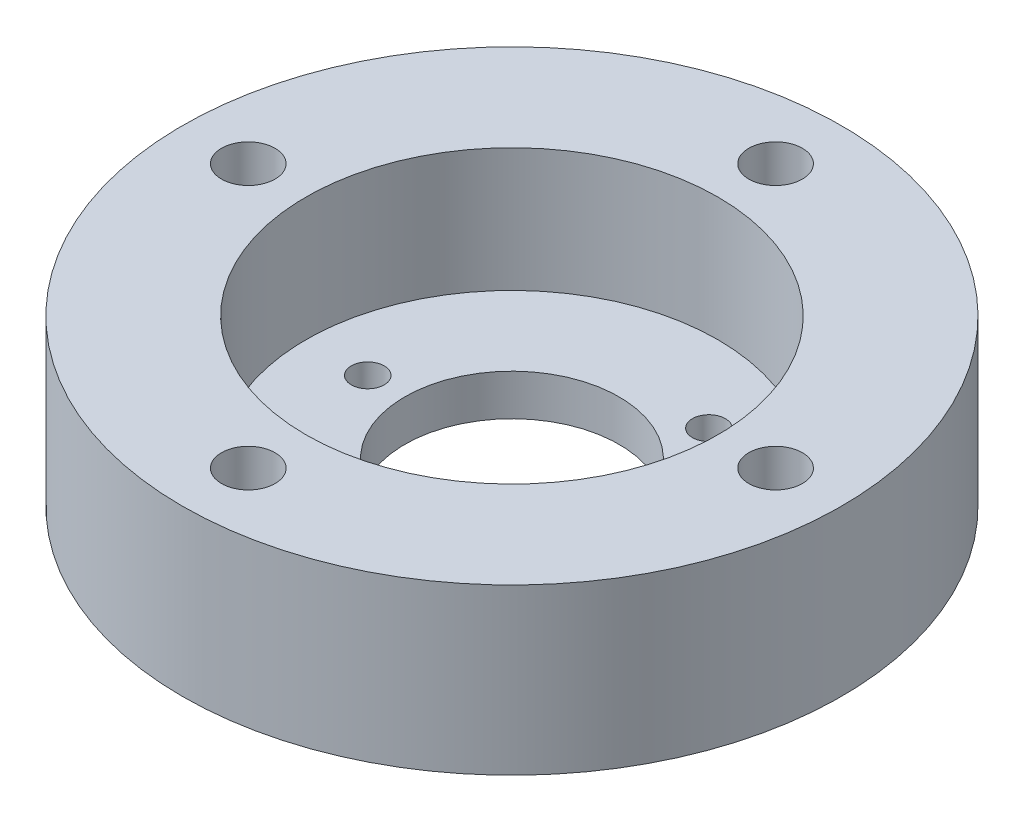
from build123d import *

# Parameters (mm, degrees)
SKETCH2_R          = 2
CUT_EXTRUDE1_DEPTH = 21
SKETCH3_R          = 3.25
CUT_EXTRUDE2_DEPTH = 21
CIRPATTERN1_COUNT  = 4
CIRPATTERN2_COUNT  = 3


with BuildPart() as part:
    # Sketch1 → Revolve1 (revolve)
    with BuildSketch(Plane.XY):
        Polygon((13, 0), (13, 5), (25, 5), (25, 20), (40, 20), (40, 0), align=None)
    revolve(axis=Axis((0, 51.395093442, 0), (0, -1, 0)))

    # Sketch2 → Cut-Extrude1 (cut, through all)
    with BuildSketch(Plane(origin=(0, 20, 0), x_dir=(1, 0, 0), z_dir=(0, 1, 0))):
        with Locations((-17.5, 0)):
            Circle(SKETCH2_R)
    cut_extrude1 = extrude(amount=-CUT_EXTRUDE1_DEPTH, mode=Mode.SUBTRACT)

    # Sketch3 → Cut-Extrude2 (cut, through all)
    with BuildSketch(Plane(origin=(0, 20, 0), x_dir=(1, 0, 0), z_dir=(0, 1, 0))):
        with Locations((0, 32)):
            Circle(SKETCH3_R)
    cut_extrude2 = extrude(amount=-CUT_EXTRUDE2_DEPTH, mode=Mode.SUBTRACT)

    # CirPattern1: Cut-Extrude2 ×4 about axis
    cirpattern1_axis = Axis((0, 0, 0), (0, 1, 0))
    for i in range(1, CIRPATTERN1_COUNT):
        add(cut_extrude2.rotate(cirpattern1_axis, i * 360 / CIRPATTERN1_COUNT), mode=Mode.SUBTRACT)

    # CirPattern2: Cut-Extrude1 ×3 about axis
    cirpattern2_axis = Axis((0, 0, 0), (0, 1, 0))
    for i in range(1, CIRPATTERN2_COUNT):
        add(cut_extrude1.rotate(cirpattern2_axis, i * 360 / CIRPATTERN2_COUNT), mode=Mode.SUBTRACT)


solid = part.part
